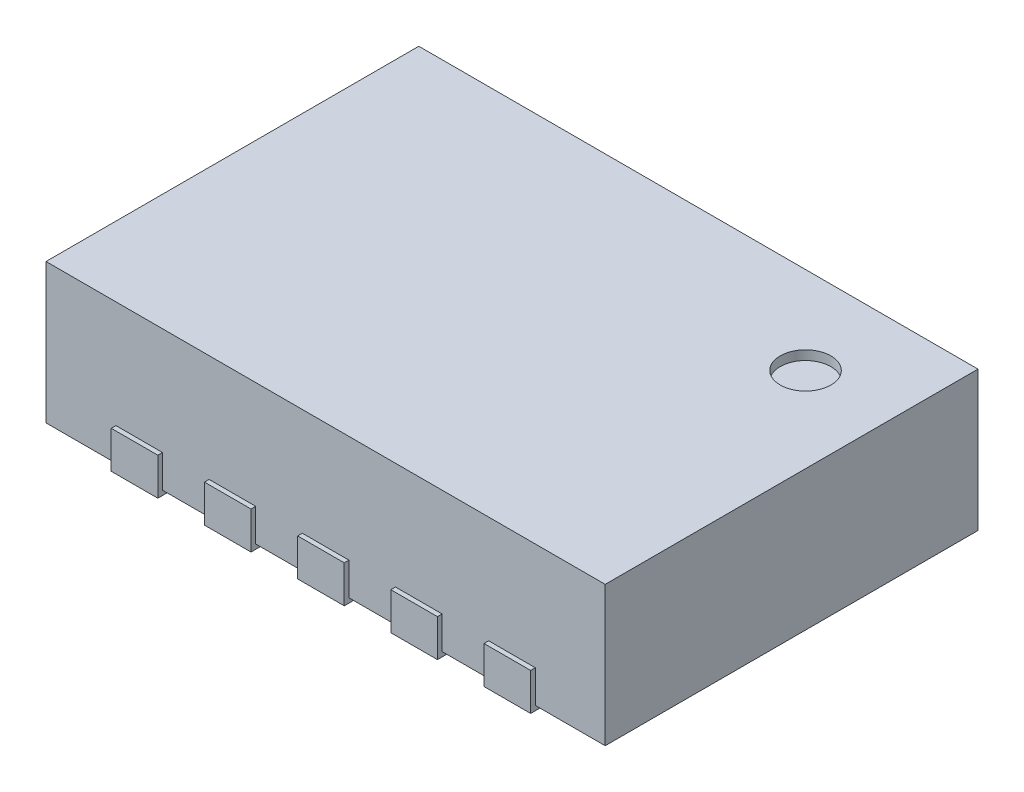
from build123d import *

# Parameters (mm, degrees)
SKETCH1_W           = 3
SKETCH1_H           = 2
BOSS_EXTRUDE1_DEPTH = 0.75
SKETCH2_W           = 0.25
SKETCH2_H           = 0.3
SKETCH2_W_2         = 2.458211199
SKETCH2_H_2         = 0.544287264
BOSS_EXTRUDE2_DEPTH = 0.025
CUT_EXTRUDE1_DEPTH  = 0.025
SKETCH8_W           = 0.25
SKETCH8_H           = 0.2
BOSS_EXTRUDE3_DEPTH = 0.025
BOSS_EXTRUDE4_DEPTH = 0.025
SKETCH10_R          = 0.135779542
CUT_EXTRUDE2_DEPTH  = 0.05


with BuildPart() as part:
    # Sketch1 → Boss-Extrude1 (new body)
    with BuildSketch(Plane(origin=(0, 0, 0), x_dir=(1, 0, 0), z_dir=(0, 1, 0))):
        with Locations((-26.317781221, 19.983079484)):
            Rectangle(SKETCH1_W, SKETCH1_H)
    extrude(amount=BOSS_EXTRUDE1_DEPTH)

    # Sketch2 → Boss-Extrude2 (add)
    with BuildSketch(Plane.XZ):
        with Locations((-25.817781221, -20.833079484)):
            Rectangle(SKETCH2_W, SKETCH2_H)
        with Locations((-25.317781221, -20.833079484)):
            Rectangle(SKETCH2_W, SKETCH2_H)
        with Locations((-26.317781221, -20.833079484)):
            Rectangle(SKETCH2_W, SKETCH2_H)
        with Locations((-26.817781221, -20.833079484)):
            Rectangle(SKETCH2_W, SKETCH2_H)
        with Locations((-27.317781221, -20.833079484)):
            Rectangle(SKETCH2_W, SKETCH2_H)
        with Locations((-26.817781221, -19.133079484)):
            Rectangle(SKETCH2_W, SKETCH2_H)
        with Locations((-27.317781221, -19.133079484)):
            Rectangle(SKETCH2_W, SKETCH2_H)
        with Locations((-26.317781221, -19.133079484)):
            Rectangle(SKETCH2_W, SKETCH2_H)
        with Locations((-25.817781221, -19.133079484)):
            Rectangle(SKETCH2_W, SKETCH2_H)
        with Locations((-25.317781221, -19.133079484)):
            Rectangle(SKETCH2_W, SKETCH2_H)
        with Locations((-26.317781221, -19.983079484)):
            Rectangle(SKETCH2_W_2, SKETCH2_H_2)
    extrude(amount=BOSS_EXTRUDE2_DEPTH)

    # Sketch3 → Cut-Extrude1 (cut)
    with BuildSketch(Plane(origin=(0, -0.025, 0), x_dir=(-1, 0, 0), z_dir=(0, -1, 0))):
        Polygon((25.088675621, 20.12010835), (25.223675621, 20.255223116), (25.088675621, 20.255223116), align=None)
    extrude(amount=-CUT_EXTRUDE1_DEPTH, mode=Mode.SUBTRACT)

    # Sketch8 → Boss-Extrude3 (add)
    with BuildSketch(Plane.XY.offset(-18.983079484)):
        with Locations((-27.317781221, 0.075)):
            Rectangle(SKETCH8_W, SKETCH8_H)
        with Locations((-26.817781221, 0.075)):
            Rectangle(SKETCH8_W, SKETCH8_H)
        with Locations((-26.317781221, 0.075)):
            Rectangle(SKETCH8_W, SKETCH8_H)
        with Locations((-25.817781221, 0.075)):
            Rectangle(SKETCH8_W, SKETCH8_H)
        with Locations((-25.317781221, 0.075)):
            Rectangle(SKETCH8_W, SKETCH8_H)
    extrude(amount=BOSS_EXTRUDE3_DEPTH)

    # Sketch5 → Boss-Extrude4 (add)
    with BuildSketch(Plane(origin=(0, 0, -20.983079484), x_dir=(-1, 0, 0), z_dir=(0, 0, -1))):
        Polygon((25.192781221, 0), (25.192781221, -0.025), (25.442781221, -0.025), (25.442781221, 0), (25.442781221, 0.175), (25.192781221, 0.175), align=None)
        Polygon((25.692781221, 0), (25.692781221, -0.025), (25.942781221, -0.025), (25.942781221, 0), (25.942781221, 0.175), (25.692781221, 0.175), align=None)
        Polygon((26.192781221, 0), (26.192781221, -0.025), (26.442781221, -0.025), (26.442781221, 0), (26.442781221, 0.175), (26.192781221, 0.175), align=None)
        Polygon((26.692781221, 0), (26.692781221, -0.025), (26.942781221, -0.025), (26.942781221, 0), (26.942781221, 0.175), (26.692781221, 0.175), align=None)
        Polygon((27.192781221, 0), (27.192781221, -0.025), (27.442781221, -0.025), (27.442781221, 0), (27.442781221, 0.175), (27.192781221, 0.175), align=None)
    extrude(amount=BOSS_EXTRUDE4_DEPTH)

    # Sketch10 → Cut-Extrude2 (cut)
    with BuildSketch(Plane(origin=(0, 0.75, 0), x_dir=(1, 0, 0), z_dir=(0, 1, 0))):
        with Locations(Location((-25.274148522, 20.514267266, 0), (0, 0, 270))):
            Circle(SKETCH10_R)
    extrude(amount=-CUT_EXTRUDE2_DEPTH, mode=Mode.SUBTRACT)


solid = part.part
